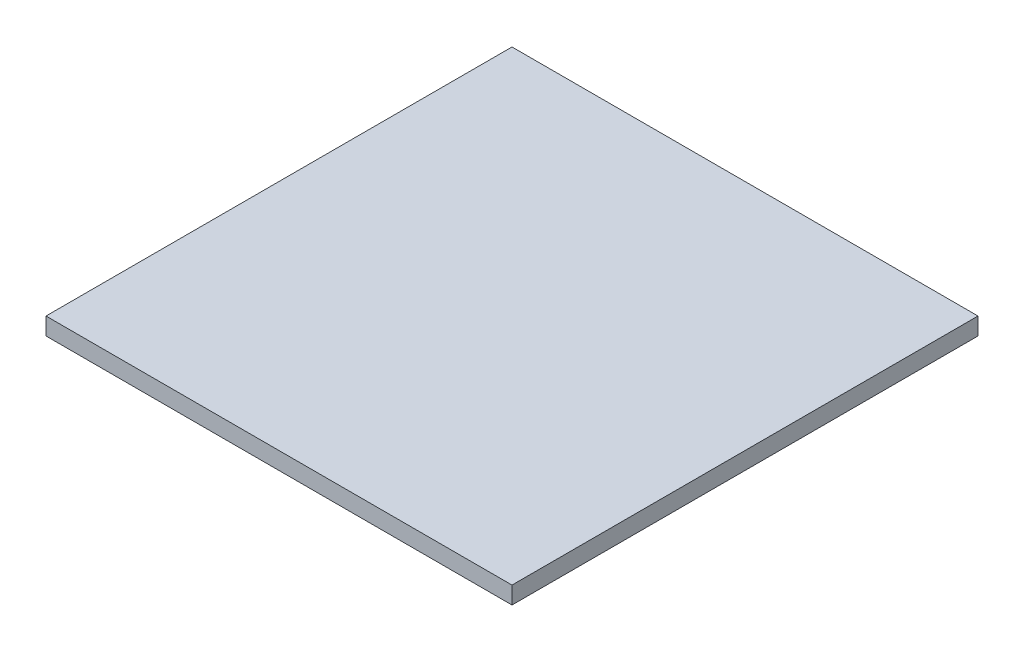
from build123d import *

# Parameters (mm, degrees)
ESQUISSE1_W             = 7
ESQUISSE1_H             = 7
BOSS_EXTRU_1_DEPTH      = 0.26
ESQUISSE2_W             = 5.4
ESQUISSE2_H             = 5.4
BOSS_EXTRU_2_DEPTH      = 0.01
ESQUISSE5_W             = 0.4
ESQUISSE5_H             = 0.25
BOSS_EXTRU_5_DEPTH      = 0.01
ESQUISSE6_W             = 0.25
ESQUISSE6_H             = 0.4
BOSS_EXTRU_6_DEPTH      = 0.01
ENL_V_MAT_EXTRU_1_DEPTH = 0.01


with BuildPart() as part:
    # Esquisse1 → Boss.-Extru.1 (new body)
    with BuildSketch(Plane(origin=(0, 0, 0), x_dir=(1, 0, 0), z_dir=(0, 1, 0))):
        with Locations((3.5, 3.5)):
            Rectangle(ESQUISSE1_W, ESQUISSE1_H)
    extrude(amount=BOSS_EXTRU_1_DEPTH)

    # Esquisse2 → Boss.-Extru.2 (add)
    with BuildSketch(Plane.XZ):
        with Locations((3.5, -3.5)):
            Rectangle(ESQUISSE2_W, ESQUISSE2_H)
    extrude(amount=BOSS_EXTRU_2_DEPTH)

    # Esquisse5 → Boss.-Extru.5 (add)
    with BuildSketch(Plane.XZ):
        with Locations((0.275, -5.806205718)):
            Rectangle(ESQUISSE5_W, ESQUISSE5_H)
        with Locations((0.275, -6.306205718)):
            Rectangle(ESQUISSE5_W, ESQUISSE5_H)
        with Locations((0.275, -5.306205718)):
            Rectangle(ESQUISSE5_W, ESQUISSE5_H)
        with Locations((0.275, -4.806205718)):
            Rectangle(ESQUISSE5_W, ESQUISSE5_H)
        with Locations((0.275, -4.306205718)):
            Rectangle(ESQUISSE5_W, ESQUISSE5_H)
        with Locations((0.275, -3.806205718)):
            Rectangle(ESQUISSE5_W, ESQUISSE5_H)
        with Locations((0.275, -3.306205718)):
            Rectangle(ESQUISSE5_W, ESQUISSE5_H)
        with Locations((0.275, -2.806205718)):
            Rectangle(ESQUISSE5_W, ESQUISSE5_H)
        with Locations((0.275, -2.306205718)):
            Rectangle(ESQUISSE5_W, ESQUISSE5_H)
        with Locations((0.275, -1.806205718)):
            Rectangle(ESQUISSE5_W, ESQUISSE5_H)
        with Locations((0.275, -1.306205718)):
            Rectangle(ESQUISSE5_W, ESQUISSE5_H)
        with Locations((0.275, -0.806205718)):
            Rectangle(ESQUISSE5_W, ESQUISSE5_H)
        with Locations((6.725, -0.806205718)):
            Rectangle(ESQUISSE5_W, ESQUISSE5_H)
        with Locations((6.725, -1.306205718)):
            Rectangle(ESQUISSE5_W, ESQUISSE5_H)
        with Locations((6.725, -1.806205718)):
            Rectangle(ESQUISSE5_W, ESQUISSE5_H)
        with Locations((6.725, -2.306205718)):
            Rectangle(ESQUISSE5_W, ESQUISSE5_H)
        with Locations((6.725, -2.806205718)):
            Rectangle(ESQUISSE5_W, ESQUISSE5_H)
        with Locations((6.725, -3.306205718)):
            Rectangle(ESQUISSE5_W, ESQUISSE5_H)
        with Locations((6.725, -3.806205718)):
            Rectangle(ESQUISSE5_W, ESQUISSE5_H)
        with Locations((6.725, -4.306205718)):
            Rectangle(ESQUISSE5_W, ESQUISSE5_H)
        with Locations((6.725, -4.806205718)):
            Rectangle(ESQUISSE5_W, ESQUISSE5_H)
        with Locations((6.725, -5.306205718)):
            Rectangle(ESQUISSE5_W, ESQUISSE5_H)
        with Locations((6.725, -5.806205718)):
            Rectangle(ESQUISSE5_W, ESQUISSE5_H)
        with Locations((6.725, -6.306205718)):
            Rectangle(ESQUISSE5_W, ESQUISSE5_H)
    extrude(amount=BOSS_EXTRU_5_DEPTH)

    # Esquisse6 → Boss.-Extru.6 (add)
    with BuildSketch(Plane.XZ):
        with Locations((5.773747591, -6.724517983)):
            Rectangle(ESQUISSE6_W, ESQUISSE6_H)
        with Locations((6.273747591, -6.724517983)):
            Rectangle(ESQUISSE6_W, ESQUISSE6_H)
        with Locations((5.273747591, -6.724517983)):
            Rectangle(ESQUISSE6_W, ESQUISSE6_H)
        with Locations((4.773747591, -6.724517983)):
            Rectangle(ESQUISSE6_W, ESQUISSE6_H)
        with Locations((4.273747591, -6.724517983)):
            Rectangle(ESQUISSE6_W, ESQUISSE6_H)
        with Locations((3.773747591, -6.724517983)):
            Rectangle(ESQUISSE6_W, ESQUISSE6_H)
        with Locations((3.273747591, -6.724517983)):
            Rectangle(ESQUISSE6_W, ESQUISSE6_H)
        with Locations((2.773747591, -6.724517983)):
            Rectangle(ESQUISSE6_W, ESQUISSE6_H)
        with Locations((2.273747591, -6.724517983)):
            Rectangle(ESQUISSE6_W, ESQUISSE6_H)
        with Locations((1.773747591, -6.724517983)):
            Rectangle(ESQUISSE6_W, ESQUISSE6_H)
        with Locations((1.273747591, -6.724517983)):
            Rectangle(ESQUISSE6_W, ESQUISSE6_H)
        with Locations((0.773747591, -6.724517983)):
            Rectangle(ESQUISSE6_W, ESQUISSE6_H)
        with Locations((2.273747591, -0.275482017)):
            Rectangle(ESQUISSE6_W, ESQUISSE6_H)
        with Locations((0.773747591, -0.275482017)):
            Rectangle(ESQUISSE6_W, ESQUISSE6_H)
        with Locations((1.273747591, -0.275482017)):
            Rectangle(ESQUISSE6_W, ESQUISSE6_H)
        with Locations((1.773747591, -0.275482017)):
            Rectangle(ESQUISSE6_W, ESQUISSE6_H)
        with Locations((2.773747591, -0.275482017)):
            Rectangle(ESQUISSE6_W, ESQUISSE6_H)
        with Locations((3.273747591, -0.275482017)):
            Rectangle(ESQUISSE6_W, ESQUISSE6_H)
        with Locations((3.773747591, -0.275482017)):
            Rectangle(ESQUISSE6_W, ESQUISSE6_H)
        with Locations((4.273747591, -0.275482017)):
            Rectangle(ESQUISSE6_W, ESQUISSE6_H)
        with Locations((4.773747591, -0.275482017)):
            Rectangle(ESQUISSE6_W, ESQUISSE6_H)
        with Locations((5.273747591, -0.275482017)):
            Rectangle(ESQUISSE6_W, ESQUISSE6_H)
        with Locations((5.773747591, -0.275482017)):
            Rectangle(ESQUISSE6_W, ESQUISSE6_H)
        with Locations((6.273747591, -0.275482017)):
            Rectangle(ESQUISSE6_W, ESQUISSE6_H)
    extrude(amount=BOSS_EXTRU_6_DEPTH)

    # Esquisse8 → Enlèv. mat.-Extru.1 (cut)
    with BuildSketch(Plane.XZ.offset(0.01)):
        Polygon((0.8, -6.2), (1.05, -6.2), (0.8, -5.95402016), align=None)
    extrude(amount=-ENL_V_MAT_EXTRU_1_DEPTH, mode=Mode.SUBTRACT)


solid = part.part
